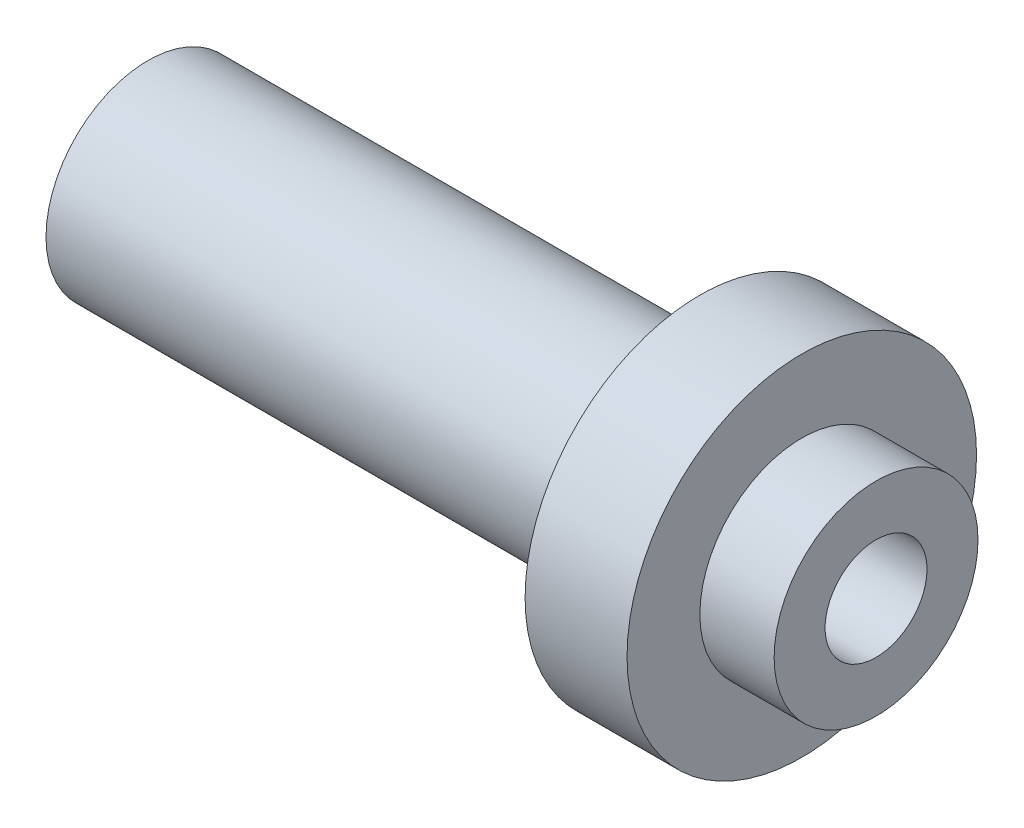
from build123d import *

# Parameters (mm, degrees)
TROU_TARAUD_M8X1_01_D     = 7
TROU_TARAUD_M8X1_01_DEPTH = 30
TROU_TARAUD_M8X1_01_TIP   = 2.103012167


with BuildPart() as part:
    # Sketch1 → Revolve1 (revolve)
    with BuildSketch(Plane.XY):
        Polygon((-5.1, 12), (-5.1, 7), (0, 7), (0, 0), (-50, 0), (-50, 7), (-12.1, 7), (-12.1, 12), align=None)
    revolve(axis=Axis((-78.343949045, 0, 0), (1, 0, 0)))

    # Trou taraudé M8x1.01
    with Locations(Plane(origin=(0, 0, 0), x_dir=(0, 0, -1), z_dir=(1, 0, 0))):
        with Locations((0, 0)):
            Hole(TROU_TARAUD_M8X1_01_D / 2, depth=TROU_TARAUD_M8X1_01_DEPTH)
            with Locations((0, 0, -(TROU_TARAUD_M8X1_01_DEPTH + TROU_TARAUD_M8X1_01_TIP / 2))):  # 118° drill point
                Cone(0, TROU_TARAUD_M8X1_01_D / 2, TROU_TARAUD_M8X1_01_TIP, mode=Mode.SUBTRACT)


solid = part.part
